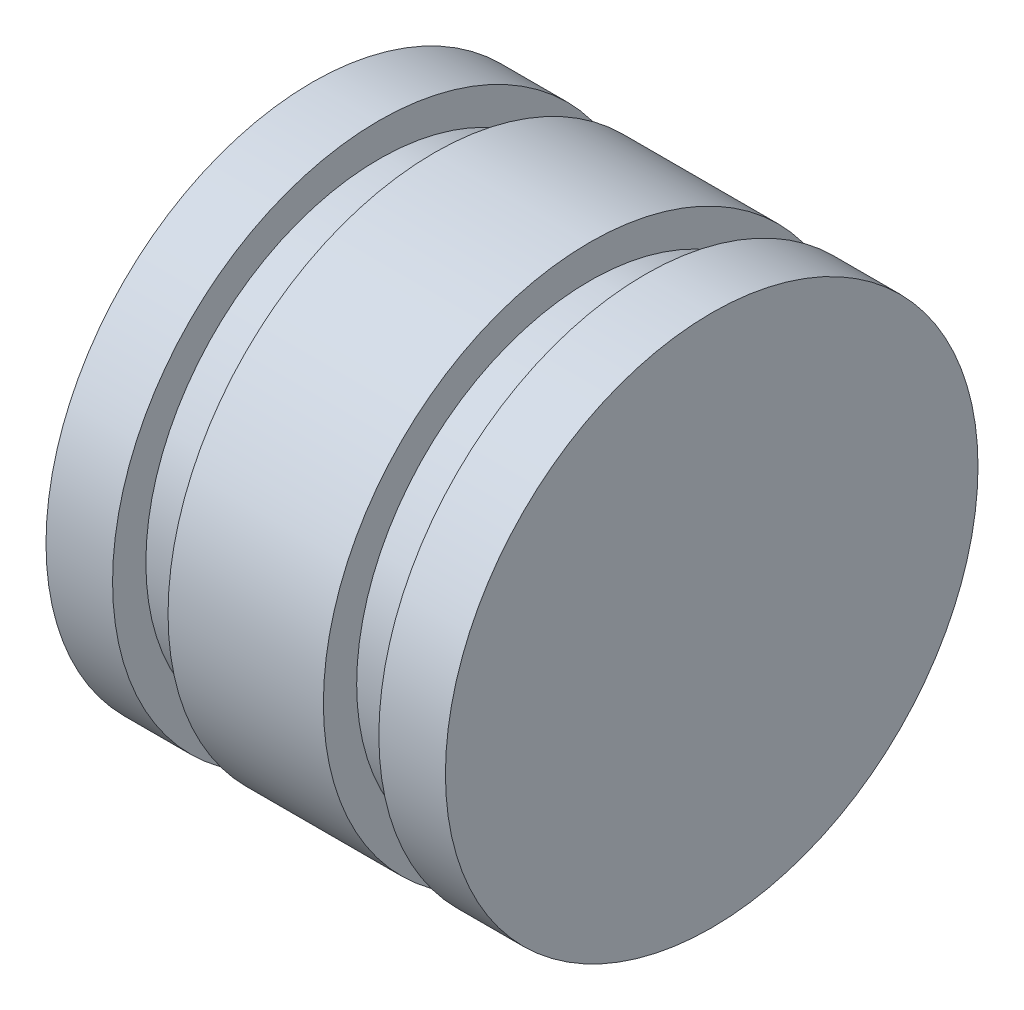
from build123d import *


with BuildPart() as part:
    # Sketch1 → Revolve1 (revolve)
    with BuildSketch(Plane(origin=(0, 0, 0), x_dir=(1, 0, 0), z_dir=(0, 1, 0))):
        Polygon((-18.319295777, -5.606060606), (-18.319295777, -4.106060606), (-15.819295777, -4.106060606), (-15.819295777, -5.606060606), (-8.819295777, -5.606060606), (-8.819295777, -4.106060606), (-6.319295777, -4.106060606), (-6.319295777, -5.606060606), (-3.319295777, -5.606060606), (-3.319295777, 6.393939394), (-21.319295777, 6.393939394), (-21.319295777, -5.606060606), align=None)
    revolve(axis=Axis((-21.319295777, 0, -6.393939394), (1, 0, 0)))


solid = part.part
